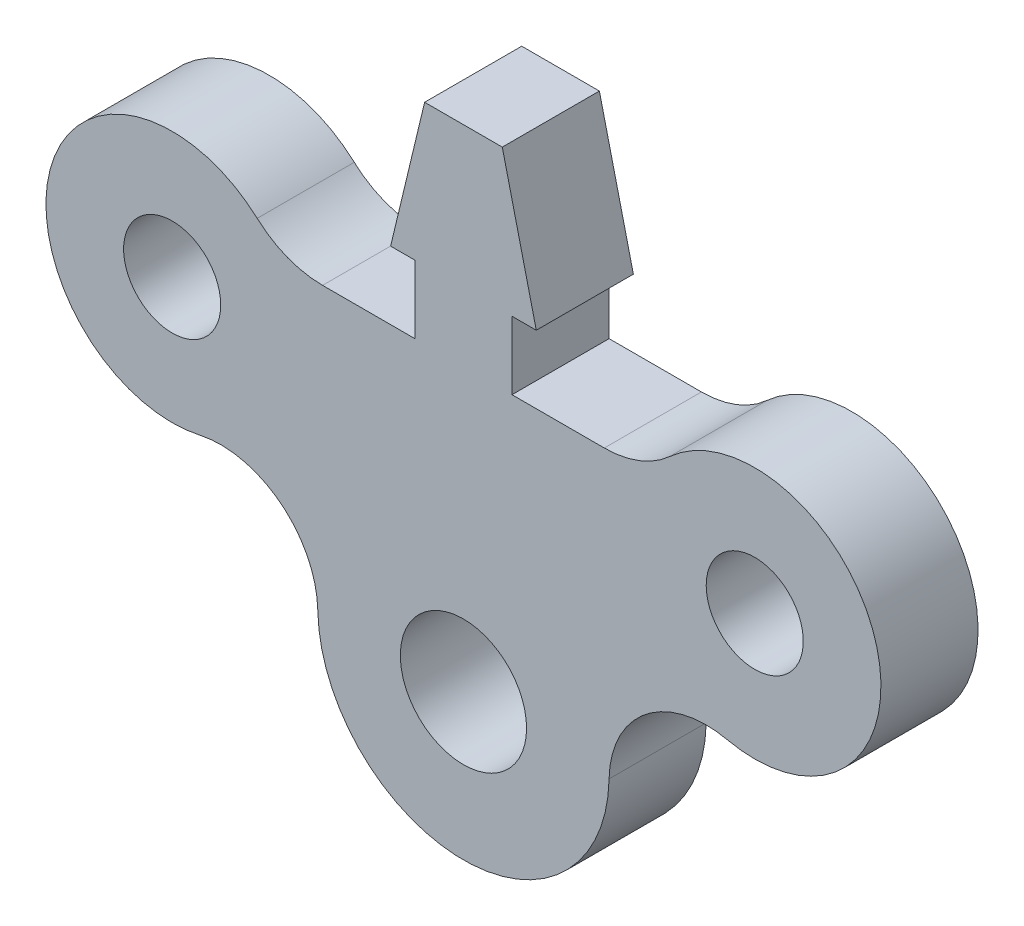
from build123d import *

# Parameters (mm, degrees)
SKETCH1_R           = 5
SKETCH1_R_2         = 6.5
BOSS_EXTRUDE1_DEPTH = 10


with BuildPart() as part:
    # Sketch1 → Boss-Extrude1 (new body)
    with BuildSketch(Plane.XY):
        with BuildLine():
            Line((14.452049987, 10.106578028), (4.943983372, 10.106578028))
            ThreePointArc((4.943983372, 10.106578028), (1.33240778, 10.781529946), (-1.791639839, 12.715273681))
            ThreePointArc((-1.791639839, 12.715273681), (-23.111525629, 6.446722896), (-7.719583441, -9.58201301))
            ThreePointArc((-7.719583441, -9.58201301), (0.640486438, -11.484150022), (4.454469887, -19.162849381))
            ThreePointArc((4.454469887, -19.162849381), (19.452049987, -33.893421972), (34.449630088, -19.162849381))
            ThreePointArc((34.449630088, -19.162849381), (38.263613537, -11.484150022), (46.623683415, -9.58201301))
            ThreePointArc((46.623683415, -9.58201301), (62.015625604, 6.446722896), (40.695739813, 12.715273681))
            ThreePointArc((40.695739813, 12.715273681), (37.571692195, 10.781529946), (33.960116603, 10.106578028))
            Line((33.960116603, 10.106578028), (24.452049987, 10.106578028))
            Line((24.452049987, 10.106578028), (24.452049987, 17.106578028))
            Line((24.452049987, 17.106578028), (26.952049987, 17.106578028))
            Line((26.952049987, 17.106578028), (23.451304138, 31.692351182))
            Line((23.451304138, 31.692351182), (19.452049987, 31.692351182))
            Line((19.452049987, 31.692351182), (15.452795837, 31.692351182))
            Line((15.452795837, 31.692351182), (11.952049987, 17.106578028))
            Line((11.952049987, 17.106578028), (14.452049987, 17.106578028))
            Line((14.452049987, 17.106578028), (14.452049987, 10.106578028))
        make_face()
        with Locations((-10.547950013, 3.106578028)):
            Circle(SKETCH1_R, mode=Mode.SUBTRACT)
        with Locations((49.452049987, 3.106578028)):
            Circle(SKETCH1_R, mode=Mode.SUBTRACT)
        with Locations((19.452049987, -18.893421972)):
            Circle(SKETCH1_R_2, mode=Mode.SUBTRACT)
    extrude(amount=BOSS_EXTRUDE1_DEPTH)


solid = part.part
